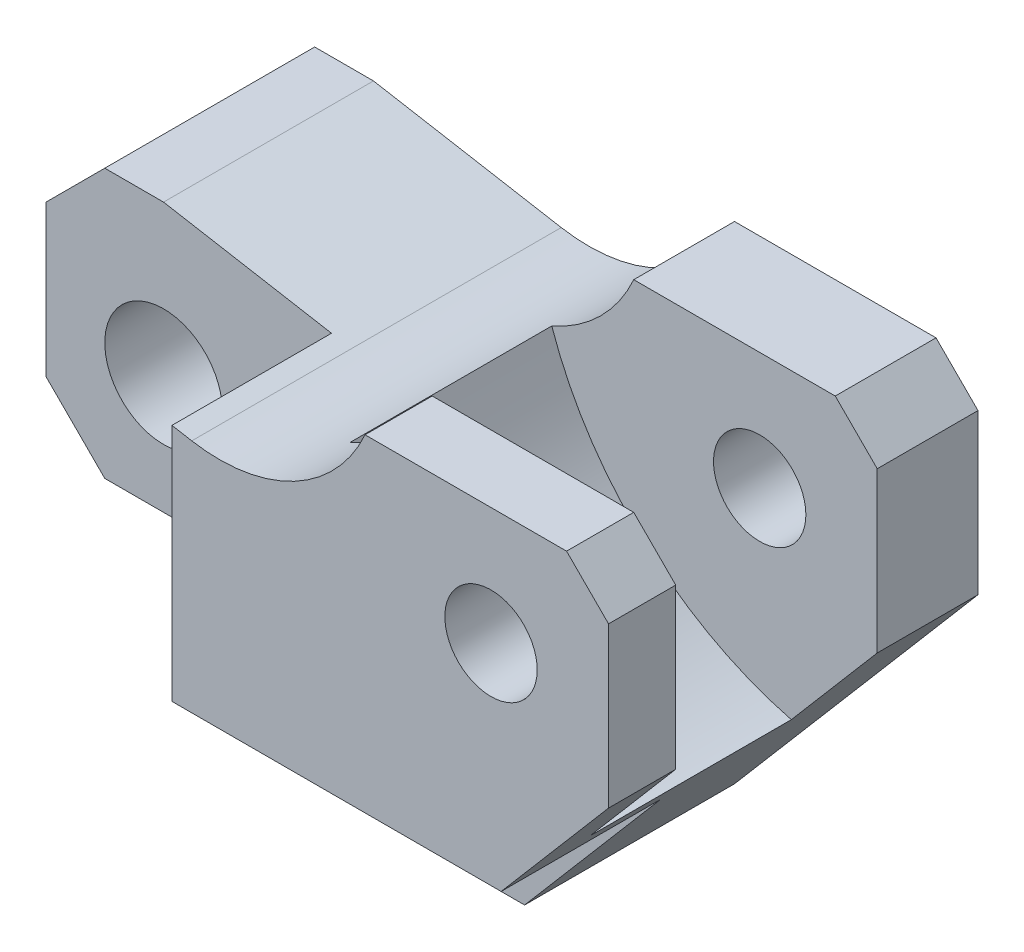
from build123d import *

# Parameters (mm, degrees)
SKETCH1_R           = 7
BOSS_EXTRUDE1_DEPTH = 44
SKETCH1_5_R         = 7
CUT_EXTRUDE1_DEPTH  = 19
SKETCH1_6_R         = 5.5
CUT_EXTRUDE2_DEPTH  = 93.460802506
CUT_EXTRUDE3_START  = -8
SKETCH1_7_R         = 5.5
CUT_EXTRUDE3_DEPTH  = 24


with BuildPart() as part:
    # Sketch1 → Boss-Extrude1 (new body)
    with BuildSketch(Plane.XY):
        with BuildLine():
            Line((0, 0), (29, 34))
            Line((29, 34), (29, 53))
            Line((29, 53), (24, 58))
            Line((24, 58), (0, 58))
            ThreePointArc((0, 58), (-8.438901294, 48.982044142), (-20.638619164, 47.057085233))
            Line((-20.638619164, 47.057085233), (-43, 51))
            Line((-43, 51), (-50, 51))
            Line((-50, 51), (-57, 44))
            Line((-57, 44), (-57, 26))
            Line((-57, 26), (-50, 19))
            Line((-50, 19), (-17.424461089, 19))
            ThreePointArc((-17.424461089, 19), (-14.159225308, 17.786586232), (-12.478822347, 14.735294118))
            ThreePointArc((-12.478822347, 14.735294118), (-10.141992144, 6.884327939), (-5.703019947, 0))
            Line((-5.703019947, 0), (0, 0))
        make_face()
        with Locations((-43, 33)):
            Circle(SKETCH1_R, mode=Mode.SUBTRACT)
    extrude(amount=-BOSS_EXTRUDE1_DEPTH)

    # Sketch1_5 → Cut-Extrude1 (cut)
    # profile 1 of 2: a face of its own
    with BuildSketch(Plane.XY):
        with BuildLine():
            Line((-5.703019947, 0), (0, 0))
            Line((0, 0), (16.205882353, 19))
            Line((16.205882353, 19), (-17.424461089, 19))
            ThreePointArc((-17.424461089, 19), (-14.159225308, 17.786586232), (-12.478822347, 14.735294118))
            ThreePointArc((-12.478822347, 14.735294118), (-10.141992144, 6.884327939), (-5.703019947, 0))
        make_face()
    # profile 2 of 2: a face of its own
    with BuildSketch(Plane.XY):
        Polygon((-50, 19), (-23, 19), (-23, 47.473460386), (-43, 51), (-50, 51), (-57, 44), (-57, 26), align=None)
        with Locations((-43, 33)):
            Circle(SKETCH1_5_R, mode=Mode.SUBTRACT)
    extrude(amount=-CUT_EXTRUDE1_DEPTH, mode=Mode.SUBTRACT)

    # Sketch1_6 → Cut-Extrude2 (cut, through all)
    with BuildSketch(Plane.XY):
        with Locations((15, 44)):
            Circle(SKETCH1_6_R)
    extrude(amount=-CUT_EXTRUDE2_DEPTH, mode=Mode.SUBTRACT)

    # Sketch1_7 → Cut-Extrude3 (cut)
    with BuildSketch(Plane.XY.offset(CUT_EXTRUDE3_START)):
        with BuildLine():
            ThreePointArc((-9.763063451, 48.344294617), (1.184262982, 31.580705229), (18.764705882, 22))
            Line((18.764705882, 22), (29, 34))
            Line((29, 34), (29, 53))
            Line((29, 53), (24, 58))
            Line((24, 58), (0, 58))
            ThreePointArc((0, 58), (-3.978755657, 52.259333621), (-9.763063451, 48.344294617))
        make_face()
        with Locations((15, 44)):
            Circle(SKETCH1_7_R, mode=Mode.SUBTRACT)
    extrude(amount=-CUT_EXTRUDE3_DEPTH, mode=Mode.SUBTRACT)


solid = part.part
